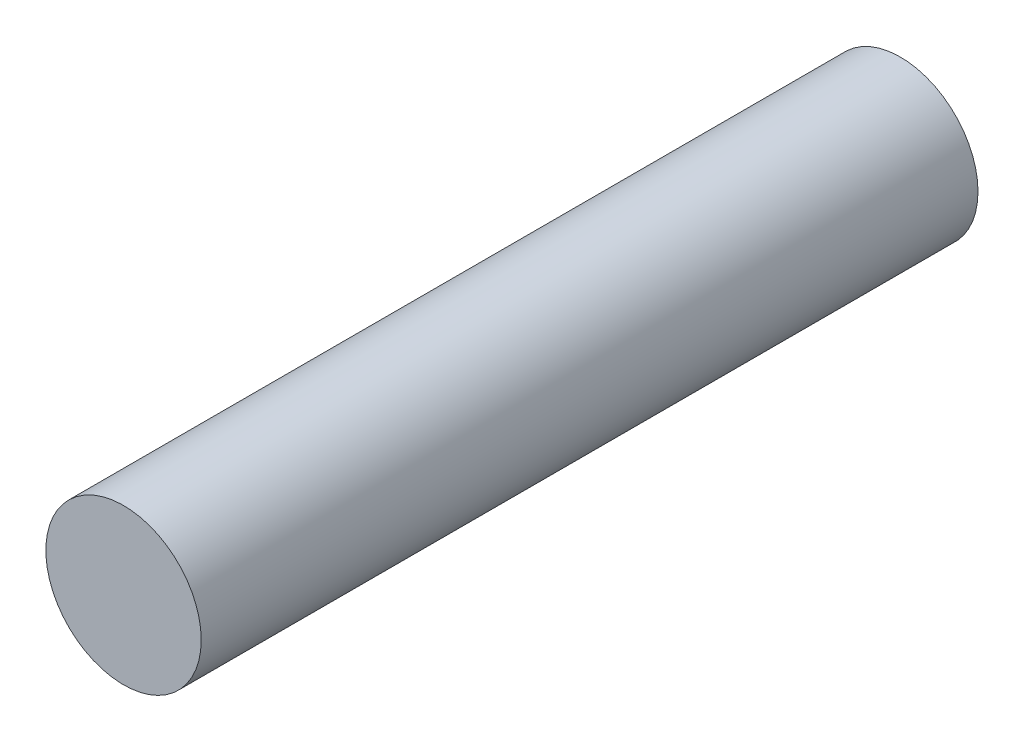
from build123d import *

# Parameters (mm, degrees)
SKETCH2_R           = 2
BOSS_EXTRUDE1_DEPTH = 20


with BuildPart() as part:
    # Sketch2 → Boss-Extrude1 (new body)
    with BuildSketch(Plane.XY):
        with Locations((0.028629917, 0.057259833)):
            Circle(SKETCH2_R)
    extrude(amount=BOSS_EXTRUDE1_DEPTH)


solid = part.part
